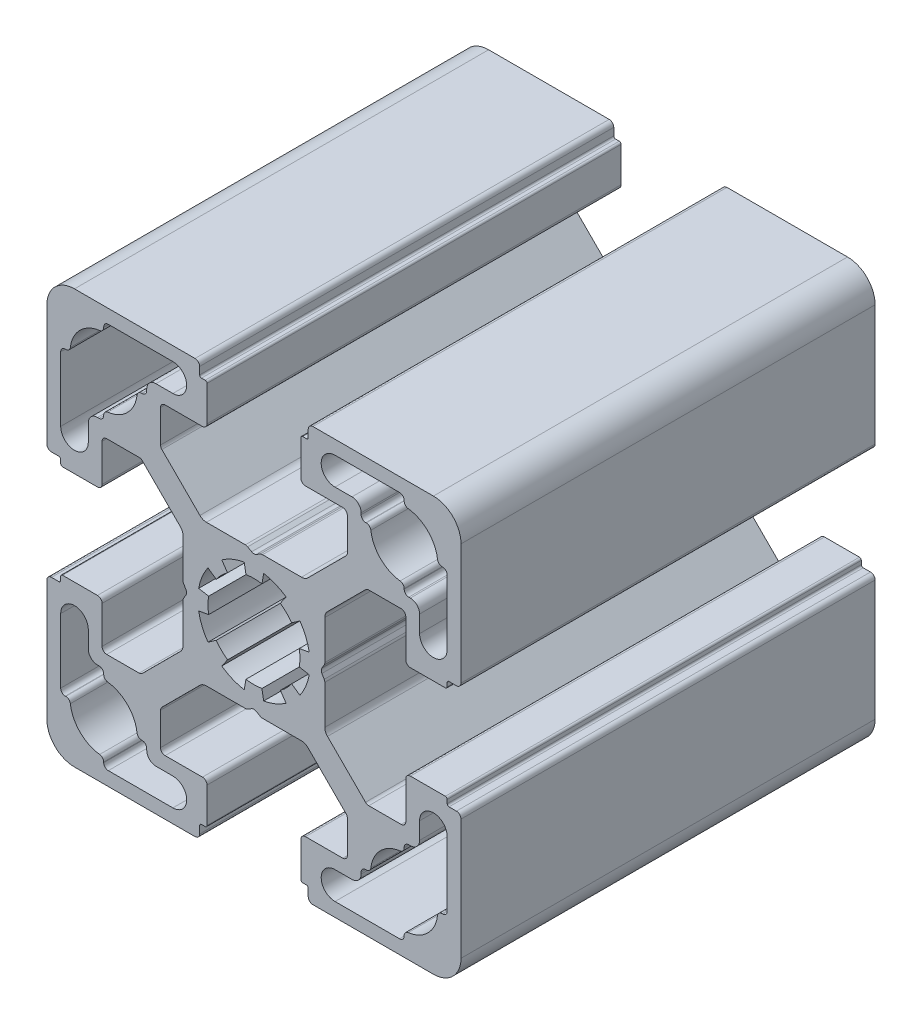
from build123d import *

# Parameters (mm, degrees)
EXTRUDE_4_DEPTH = 45


with BuildPart() as part:
    # Эскиз1 → Бобышка-Вытянуть4 (new body)
    with BuildSketch(Plane.XY):
        with BuildLine():
            Line((-7.700480433, 0.929088242), (-7.700480433, 5.164946528))
            ThreePointArc((-7.700480433, 5.164946528), (-7.776600901, 5.54762996), (-7.993373652, 5.872053309))
            Line((-7.993373652, 5.872053309), (-10.240131415, 8.118811071))
            Line((-10.240131415, 8.118811071), (-12.124873734, 10.003553391))
            ThreePointArc((-12.124873734, 10.003553391), (-12.287085409, 10.111939766), (-12.478427125, 10.15))
            Line((-12.478427125, 10.15), (-16, 10.15))
            ThreePointArc((-16, 10.15), (-16.353553391, 10.003553391), (-16.5, 9.65))
            Line((-16.5, 9.65), (-16.5, 5.6))
            ThreePointArc((-16.5, 5.6), (-16.646446609, 5.246446609), (-17, 5.1))
            Line((-17, 5.1), (-20.8, 5.1))
            ThreePointArc((-20.8, 5.1), (-20.941421356, 5.158578644), (-21, 5.3))
            Line((-21, 5.3), (-21, 5.7))
            ThreePointArc((-21, 5.7), (-21.058578644, 5.841421356), (-21.2, 5.9))
            Line((-21.2, 5.9), (-22, 5.9))
            ThreePointArc((-22, 5.9), (-22.353553391, 6.046446609), (-22.5, 6.4))
            Line((-22.5, 6.4), (-22.5, 19.5))
            ThreePointArc((-22.5, 19.5), (-21.621320344, 21.621320344), (-19.5, 22.5))
            Line((-19.5, 22.5), (-6.4, 22.5))
            ThreePointArc((-6.4, 22.5), (-6.046446609, 22.353553391), (-5.9, 22))
            Line((-5.9, 22), (-5.9, 21.2))
            ThreePointArc((-5.9, 21.2), (-5.841421356, 21.058578644), (-5.7, 21))
            Line((-5.7, 21), (-5.3, 21))
            ThreePointArc((-5.3, 21), (-5.158578644, 20.941421356), (-5.1, 20.8))
            Line((-5.1, 20.8), (-5.1, 17))
            ThreePointArc((-5.1, 17), (-5.246446609, 16.646446609), (-5.6, 16.5))
            Line((-5.6, 16.5), (-9.65, 16.5))
            ThreePointArc((-9.65, 16.5), (-10.003553391, 16.353553391), (-10.15, 16))
            Line((-10.15, 16), (-10.15, 12.478427125))
            ThreePointArc((-10.15, 12.478427125), (-10.111939766, 12.287085409), (-10.003553391, 12.124873734))
            Line((-10.003553391, 12.124873734), (-8.118811071, 10.240131415))
            Line((-8.118811071, 10.240131415), (-5.872053309, 7.993373652))
            ThreePointArc((-5.872053309, 7.993373652), (-5.54762996, 7.776600901), (-5.164946528, 7.700480433))
            Line((-5.164946528, 7.700480433), (-0.929088242, 7.700480433))
            ThreePointArc((-0.929088242, 7.700480433), (-0.799678719, 7.683443347), (-0.679088242, 7.633493135))
            Line((-0.679088242, 7.633493135), (-0.25, 7.385758924))
            ThreePointArc((-0.25, 7.385758924), (0, 7.318771625), (0.25, 7.385758924))
            Line((0.25, 7.385758924), (0.679088242, 7.633493135))
            ThreePointArc((0.679088242, 7.633493135), (0.799678719, 7.683443347), (0.929088242, 7.700480433))
            Line((0.929088242, 7.700480433), (5.164946528, 7.700480433))
            ThreePointArc((5.164946528, 7.700480433), (5.54762996, 7.776600901), (5.872053309, 7.993373652))
            Line((5.872053309, 7.993373652), (8.118811071, 10.240131415))
            Line((8.118811071, 10.240131415), (10.003553391, 12.124873734))
            ThreePointArc((10.003553391, 12.124873734), (10.111939766, 12.287085409), (10.15, 12.478427125))
            Line((10.15, 12.478427125), (10.15, 16))
            ThreePointArc((10.15, 16), (10.003553391, 16.353553391), (9.65, 16.5))
            Line((9.65, 16.5), (5.6, 16.5))
            ThreePointArc((5.6, 16.5), (5.246446609, 16.646446609), (5.1, 17))
            Line((5.1, 17), (5.1, 20.8))
            ThreePointArc((5.1, 20.8), (5.158578644, 20.941421356), (5.3, 21))
            Line((5.3, 21), (5.7, 21))
            ThreePointArc((5.7, 21), (5.841421356, 21.058578644), (5.9, 21.2))
            Line((5.9, 21.2), (5.9, 22))
            ThreePointArc((5.9, 22), (6.046446609, 22.353553391), (6.4, 22.5))
            Line((6.4, 22.5), (19.5, 22.5))
            ThreePointArc((19.5, 22.5), (21.621320344, 21.621320344), (22.5, 19.5))
            Line((22.5, 19.5), (22.5, 6.4))
            ThreePointArc((22.5, 6.4), (22.353553391, 6.046446609), (22, 5.9))
            Line((22, 5.9), (21.2, 5.9))
            ThreePointArc((21.2, 5.9), (21.058578644, 5.841421356), (21, 5.7))
            Line((21, 5.7), (21, 5.3))
            ThreePointArc((21, 5.3), (20.941421356, 5.158578644), (20.8, 5.1))
            Line((20.8, 5.1), (17, 5.1))
            ThreePointArc((17, 5.1), (16.646446609, 5.246446609), (16.5, 5.6))
            Line((16.5, 5.6), (16.5, 9.65))
            ThreePointArc((16.5, 9.65), (16.353553391, 10.003553391), (16, 10.15))
            Line((16, 10.15), (12.478427125, 10.15))
            ThreePointArc((12.478427125, 10.15), (12.287085409, 10.111939766), (12.124873734, 10.003553391))
            Line((12.124873734, 10.003553391), (10.240131415, 8.118811071))
            Line((10.240131415, 8.118811071), (7.993373652, 5.872053309))
            ThreePointArc((7.993373652, 5.872053309), (7.776600901, 5.54762996), (7.700480433, 5.164946528))
            Line((7.700480433, 5.164946528), (7.700480433, 0.929088242))
            ThreePointArc((7.700480433, 0.929088242), (7.683443347, 0.799678719), (7.633493135, 0.679088242))
            Line((7.633493135, 0.679088242), (7.385758924, 0.25))
            ThreePointArc((7.385758924, 0.25), (7.318771625, 0), (7.385758924, -0.25))
            Line((7.385758924, -0.25), (7.633493135, -0.679088242))
            ThreePointArc((7.633493135, -0.679088242), (7.683443347, -0.799678719), (7.700480433, -0.929088242))
            Line((7.700480433, -0.929088242), (7.700480433, -5.164946528))
            ThreePointArc((7.700480433, -5.164946528), (7.776600901, -5.54762996), (7.993373652, -5.872053309))
            Line((7.993373652, -5.872053309), (10.240131415, -8.118811071))
            Line((10.240131415, -8.118811071), (12.124873734, -10.003553391))
            ThreePointArc((12.124873734, -10.003553391), (12.287085409, -10.111939766), (12.478427125, -10.15))
            Line((12.478427125, -10.15), (16, -10.15))
            ThreePointArc((16, -10.15), (16.353553391, -10.003553391), (16.5, -9.65))
            Line((16.5, -9.65), (16.5, -5.6))
            ThreePointArc((16.5, -5.6), (16.646446609, -5.246446609), (17, -5.1))
            Line((17, -5.1), (20.8, -5.1))
            ThreePointArc((20.8, -5.1), (20.941421356, -5.158578644), (21, -5.3))
            Line((21, -5.3), (21, -5.7))
            ThreePointArc((21, -5.7), (21.058578644, -5.841421356), (21.2, -5.9))
            Line((21.2, -5.9), (22, -5.9))
            ThreePointArc((22, -5.9), (22.353553391, -6.046446609), (22.5, -6.4))
            Line((22.5, -6.4), (22.5, -19.5))
            ThreePointArc((22.5, -19.5), (21.621320344, -21.621320344), (19.5, -22.5))
            Line((19.5, -22.5), (6.4, -22.5))
            ThreePointArc((6.4, -22.5), (6.046446609, -22.353553391), (5.9, -22))
            Line((5.9, -22), (5.9, -21.2))
            ThreePointArc((5.9, -21.2), (5.841421356, -21.058578644), (5.7, -21))
            Line((5.7, -21), (5.3, -21))
            ThreePointArc((5.3, -21), (5.158578644, -20.941421356), (5.1, -20.8))
            Line((5.1, -20.8), (5.1, -17))
            ThreePointArc((5.1, -17), (5.246446609, -16.646446609), (5.6, -16.5))
            Line((5.6, -16.5), (9.65, -16.5))
            ThreePointArc((9.65, -16.5), (10.003553391, -16.353553391), (10.15, -16))
            Line((10.15, -16), (10.15, -12.478427125))
            ThreePointArc((10.15, -12.478427125), (10.111939766, -12.287085409), (10.003553391, -12.124873734))
            Line((10.003553391, -12.124873734), (8.118811071, -10.240131415))
            Line((8.118811071, -10.240131415), (5.872053309, -7.993373652))
            ThreePointArc((5.872053309, -7.993373652), (5.54762996, -7.776600901), (5.164946528, -7.700480433))
            Line((5.164946528, -7.700480433), (0.929088242, -7.700480433))
            ThreePointArc((0.929088242, -7.700480433), (0.799678719, -7.683443347), (0.679088242, -7.633493135))
            Line((0.679088242, -7.633493135), (0.25, -7.385758924))
            ThreePointArc((0.25, -7.385758924), (0, -7.318771625), (-0.25, -7.385758924))
            Line((-0.25, -7.385758924), (-0.679088242, -7.633493135))
            ThreePointArc((-0.679088242, -7.633493135), (-0.799678719, -7.683443347), (-0.929088242, -7.700480433))
            Line((-0.929088242, -7.700480433), (-5.164946528, -7.700480433))
            ThreePointArc((-5.164946528, -7.700480433), (-5.54762996, -7.776600901), (-5.872053309, -7.993373652))
            Line((-5.872053309, -7.993373652), (-8.118811071, -10.240131415))
            Line((-8.118811071, -10.240131415), (-10.003553391, -12.124873734))
            ThreePointArc((-10.003553391, -12.124873734), (-10.111939766, -12.287085409), (-10.15, -12.478427125))
            Line((-10.15, -12.478427125), (-10.15, -16))
            ThreePointArc((-10.15, -16), (-10.003553391, -16.353553391), (-9.65, -16.5))
            Line((-9.65, -16.5), (-5.6, -16.5))
            ThreePointArc((-5.6, -16.5), (-5.246446609, -16.646446609), (-5.1, -17))
            Line((-5.1, -17), (-5.1, -20.8))
            ThreePointArc((-5.1, -20.8), (-5.158578644, -20.941421356), (-5.3, -21))
            Line((-5.3, -21), (-5.7, -21))
            ThreePointArc((-5.7, -21), (-5.841421356, -21.058578644), (-5.9, -21.2))
            Line((-5.9, -21.2), (-5.9, -22))
            ThreePointArc((-5.9, -22), (-6.046446609, -22.353553391), (-6.4, -22.5))
            Line((-6.4, -22.5), (-19.5, -22.5))
            ThreePointArc((-19.5, -22.5), (-21.621320344, -21.621320344), (-22.5, -19.5))
            Line((-22.5, -19.5), (-22.5, -6.4))
            ThreePointArc((-22.5, -6.4), (-22.353553391, -6.046446609), (-22, -5.9))
            Line((-22, -5.9), (-21.2, -5.9))
            ThreePointArc((-21.2, -5.9), (-21.058578644, -5.841421356), (-21, -5.7))
            Line((-21, -5.7), (-21, -5.3))
            ThreePointArc((-21, -5.3), (-20.941421356, -5.158578644), (-20.8, -5.1))
            Line((-20.8, -5.1), (-17, -5.1))
            ThreePointArc((-17, -5.1), (-16.646446609, -5.246446609), (-16.5, -5.6))
            Line((-16.5, -5.6), (-16.5, -9.65))
            ThreePointArc((-16.5, -9.65), (-16.353553391, -10.003553391), (-16, -10.15))
            Line((-16, -10.15), (-12.478427125, -10.15))
            ThreePointArc((-12.478427125, -10.15), (-12.287085409, -10.111939766), (-12.124873734, -10.003553391))
            Line((-12.124873734, -10.003553391), (-10.240131415, -8.118811071))
            Line((-10.240131415, -8.118811071), (-7.993373652, -5.872053309))
            ThreePointArc((-7.993373652, -5.872053309), (-7.776600901, -5.54762996), (-7.700480433, -5.164946528))
            Line((-7.700480433, -5.164946528), (-7.700480433, -0.929088242))
            ThreePointArc((-7.700480433, -0.929088242), (-7.683443347, -0.799678719), (-7.633493135, -0.679088242))
            Line((-7.633493135, -0.679088242), (-7.385758924, -0.25))
            ThreePointArc((-7.385758924, -0.25), (-7.318771625, 0), (-7.385758924, 0.25))
            Line((-7.385758924, 0.25), (-7.633493135, 0.679088242))
            ThreePointArc((-7.633493135, 0.679088242), (-7.683443347, 0.799678719), (-7.700480433, 0.929088242))
        make_face()
        with BuildLine():
            Line((-21, 15.825), (-21, 8.807951074))
            ThreePointArc((-21, 8.807951074), (-19.5, 7.307951074), (-18, 8.807951074))
            Line((-18, 8.807951074), (-18, 10.65))
            ThreePointArc((-18, 10.65), (-17.707106781, 11.357106781), (-17, 11.65))
            Line((-17, 11.65), (-16.825, 11.65))
            ThreePointArc((-16.825, 11.65), (-16.471446609, 11.796446609), (-16.325, 12.15))
            Line((-16.325, 12.15), (-16.325, 12.205230589))
            ThreePointArc((-16.325, 12.205230589), (-16.19924623, 12.536802239), (-15.885240964, 12.701588349))
            ThreePointArc((-15.885240964, 12.701588349), (-13.744060249, 13.744060249), (-12.701588349, 15.885240964))
            ThreePointArc((-12.701588349, 15.885240964), (-12.536802239, 16.19924623), (-12.205230589, 16.325))
            Line((-12.205230589, 16.325), (-12.15, 16.325))
            ThreePointArc((-12.15, 16.325), (-11.796446609, 16.471446609), (-11.65, 16.825))
            Line((-11.65, 16.825), (-11.65, 17))
            ThreePointArc((-11.65, 17), (-11.357106781, 17.707106781), (-10.65, 18))
            Line((-10.65, 18), (-8.807951074, 18))
            ThreePointArc((-8.807951074, 18), (-7.307951074, 19.5), (-8.807951074, 21))
            Line((-8.807951074, 21), (-15.825, 21))
            ThreePointArc((-15.825, 21), (-16.178553391, 20.853553391), (-16.325, 20.5))
            Line((-16.325, 20.5), (-16.325, 20.444769411))
            ThreePointArc((-16.325, 20.444769411), (-16.45075377, 20.113197761), (-16.764759036, 19.948411651))
            ThreePointArc((-16.764759036, 19.948411651), (-18.905939751, 18.905939751), (-19.948411651, 16.764759036))
            ThreePointArc((-19.948411651, 16.764759036), (-20.113197761, 16.45075377), (-20.444769411, 16.325))
            Line((-20.444769411, 16.325), (-20.5, 16.325))
            ThreePointArc((-20.5, 16.325), (-20.853553391, 16.178553391), (-21, 15.825))
        make_face(mode=Mode.SUBTRACT)
        with BuildLine():
            Line((-15.825, -21), (-8.807951074, -21))
            ThreePointArc((-8.807951074, -21), (-7.307951074, -19.5), (-8.807951074, -18))
            Line((-8.807951074, -18), (-10.65, -18))
            ThreePointArc((-10.65, -18), (-11.357106781, -17.707106781), (-11.65, -17))
            Line((-11.65, -17), (-11.65, -16.825))
            ThreePointArc((-11.65, -16.825), (-11.796446609, -16.471446609), (-12.15, -16.325))
            Line((-12.15, -16.325), (-12.205230589, -16.325))
            ThreePointArc((-12.205230589, -16.325), (-12.536802239, -16.19924623), (-12.701588349, -15.885240964))
            ThreePointArc((-12.701588349, -15.885240964), (-13.744060249, -13.744060249), (-15.885240964, -12.701588349))
            ThreePointArc((-15.885240964, -12.701588349), (-16.19924623, -12.536802239), (-16.325, -12.205230589))
            Line((-16.325, -12.205230589), (-16.325, -12.15))
            ThreePointArc((-16.325, -12.15), (-16.471446609, -11.796446609), (-16.825, -11.65))
            Line((-16.825, -11.65), (-17, -11.65))
            ThreePointArc((-17, -11.65), (-17.707106781, -11.357106781), (-18, -10.65))
            Line((-18, -10.65), (-18, -8.807951074))
            ThreePointArc((-18, -8.807951074), (-19.5, -7.307951074), (-21, -8.807951074))
            Line((-21, -8.807951074), (-21, -15.825))
            ThreePointArc((-21, -15.825), (-20.853553391, -16.178553391), (-20.5, -16.325))
            Line((-20.5, -16.325), (-20.444769411, -16.325))
            ThreePointArc((-20.444769411, -16.325), (-20.113197761, -16.45075377), (-19.948411651, -16.764759036))
            ThreePointArc((-19.948411651, -16.764759036), (-18.905939751, -18.905939751), (-16.764759036, -19.948411651))
            ThreePointArc((-16.764759036, -19.948411651), (-16.45075377, -20.113197761), (-16.325, -20.444769411))
            Line((-16.325, -20.444769411), (-16.325, -20.5))
            ThreePointArc((-16.325, -20.5), (-16.178553391, -20.853553391), (-15.825, -21))
        make_face(mode=Mode.SUBTRACT)
        with BuildLine():
            Line((15.825, 21), (8.807951074, 21))
            ThreePointArc((8.807951074, 21), (7.307951074, 19.5), (8.807951074, 18))
            Line((8.807951074, 18), (10.65, 18))
            ThreePointArc((10.65, 18), (11.357106781, 17.707106781), (11.65, 17))
            Line((11.65, 17), (11.65, 16.825))
            ThreePointArc((11.65, 16.825), (11.796446609, 16.471446609), (12.15, 16.325))
            Line((12.15, 16.325), (12.205230589, 16.325))
            ThreePointArc((12.205230589, 16.325), (12.536802239, 16.19924623), (12.701588349, 15.885240964))
            ThreePointArc((12.701588349, 15.885240964), (13.744060249, 13.744060249), (15.885240964, 12.701588349))
            ThreePointArc((15.885240964, 12.701588349), (16.19924623, 12.536802239), (16.325, 12.205230589))
            Line((16.325, 12.205230589), (16.325, 12.15))
            ThreePointArc((16.325, 12.15), (16.471446609, 11.796446609), (16.825, 11.65))
            Line((16.825, 11.65), (17, 11.65))
            ThreePointArc((17, 11.65), (17.707106781, 11.357106781), (18, 10.65))
            Line((18, 10.65), (18, 8.807951074))
            ThreePointArc((18, 8.807951074), (19.5, 7.307951074), (21, 8.807951074))
            Line((21, 8.807951074), (21, 15.825))
            ThreePointArc((21, 15.825), (20.853553391, 16.178553391), (20.5, 16.325))
            Line((20.5, 16.325), (20.444769411, 16.325))
            ThreePointArc((20.444769411, 16.325), (20.113197761, 16.45075377), (19.948411651, 16.764759036))
            ThreePointArc((19.948411651, 16.764759036), (18.905939751, 18.905939751), (16.764759036, 19.948411651))
            ThreePointArc((16.764759036, 19.948411651), (16.45075377, 20.113197761), (16.325, 20.444769411))
            Line((16.325, 20.444769411), (16.325, 20.5))
            ThreePointArc((16.325, 20.5), (16.178553391, 20.853553391), (15.825, 21))
        make_face(mode=Mode.SUBTRACT)
        with BuildLine():
            Line((-2.867882182, 4.095760221), (-3.498816262, 4.99682747))
            ThreePointArc((-3.498816262, 4.99682747), (-2.334368937, 5.635665148), (-1.059253884, 6.007327293))
            Line((-1.059253884, 6.007327293), (-0.868240888, 4.924038765))
            ThreePointArc((-0.868240888, 4.924038765), (0, 5), (0.868240888, 4.924038765))
            Line((0.868240888, 4.924038765), (1.059253884, 6.007327293))
            ThreePointArc((1.059253884, 6.007327293), (2.334368937, 5.635665148), (3.498816262, 4.99682747))
            Line((3.498816262, 4.99682747), (2.867882182, 4.095760221))
            ThreePointArc((2.867882182, 4.095760221), (3.535533906, 3.535533906), (4.095760221, 2.867882182))
            Line((4.095760221, 2.867882182), (4.99682747, 3.498816262))
            ThreePointArc((4.99682747, 3.498816262), (5.635665148, 2.334368937), (6.007327293, 1.059253884))
            Line((6.007327293, 1.059253884), (4.924038765, 0.868240888))
            ThreePointArc((4.924038765, 0.868240888), (5, 0), (4.924038765, -0.868240888))
            Line((4.924038765, -0.868240888), (6.007327293, -1.059253884))
            ThreePointArc((6.007327293, -1.059253884), (5.635665148, -2.334368937), (4.99682747, -3.498816262))
            Line((4.99682747, -3.498816262), (4.095760221, -2.867882182))
            ThreePointArc((4.095760221, -2.867882182), (3.535533906, -3.535533906), (2.867882182, -4.095760221))
            Line((2.867882182, -4.095760221), (3.498816262, -4.99682747))
            ThreePointArc((3.498816262, -4.99682747), (2.334368937, -5.635665148), (1.059253884, -6.007327293))
            Line((1.059253884, -6.007327293), (0.868240888, -4.924038765))
            ThreePointArc((0.868240888, -4.924038765), (0, -5), (-0.868240888, -4.924038765))
            Line((-0.868240888, -4.924038765), (-1.059253884, -6.007327293))
            ThreePointArc((-1.059253884, -6.007327293), (-2.334368937, -5.635665148), (-3.498816262, -4.99682747))
            Line((-3.498816262, -4.99682747), (-2.867882182, -4.095760221))
            ThreePointArc((-2.867882182, -4.095760221), (-3.535533906, -3.535533906), (-4.095760221, -2.867882182))
            Line((-4.095760221, -2.867882182), (-4.99682747, -3.498816262))
            ThreePointArc((-4.99682747, -3.498816262), (-5.635665148, -2.334368937), (-6.007327293, -1.059253884))
            Line((-6.007327293, -1.059253884), (-4.924038765, -0.868240888))
            ThreePointArc((-4.924038765, -0.868240888), (-5, 0), (-4.924038765, 0.868240888))
            Line((-4.924038765, 0.868240888), (-6.007327293, 1.059253884))
            ThreePointArc((-6.007327293, 1.059253884), (-5.635665148, 2.334368937), (-4.99682747, 3.498816262))
            Line((-4.99682747, 3.498816262), (-4.095760221, 2.867882182))
            ThreePointArc((-4.095760221, 2.867882182), (-3.535533906, 3.535533906), (-2.867882182, 4.095760221))
        make_face(mode=Mode.SUBTRACT)
        with BuildLine():
            Line((21, -15.825), (21, -8.807951074))
            ThreePointArc((21, -8.807951074), (19.5, -7.307951074), (18, -8.807951074))
            Line((18, -8.807951074), (18, -10.65))
            ThreePointArc((18, -10.65), (17.707106781, -11.357106781), (17, -11.65))
            Line((17, -11.65), (16.825, -11.65))
            ThreePointArc((16.825, -11.65), (16.471446609, -11.796446609), (16.325, -12.15))
            Line((16.325, -12.15), (16.325, -12.205230589))
            ThreePointArc((16.325, -12.205230589), (16.19924623, -12.536802239), (15.885240964, -12.701588349))
            ThreePointArc((15.885240964, -12.701588349), (13.744060249, -13.744060249), (12.701588349, -15.885240964))
            ThreePointArc((12.701588349, -15.885240964), (12.536802239, -16.19924623), (12.205230589, -16.325))
            Line((12.205230589, -16.325), (12.15, -16.325))
            ThreePointArc((12.15, -16.325), (11.796446609, -16.471446609), (11.65, -16.825))
            Line((11.65, -16.825), (11.65, -17))
            ThreePointArc((11.65, -17), (11.357106781, -17.707106781), (10.65, -18))
            Line((10.65, -18), (8.807951074, -18))
            ThreePointArc((8.807951074, -18), (7.307951074, -19.5), (8.807951074, -21))
            Line((8.807951074, -21), (15.825, -21))
            ThreePointArc((15.825, -21), (16.178553391, -20.853553391), (16.325, -20.5))
            Line((16.325, -20.5), (16.325, -20.444769411))
            ThreePointArc((16.325, -20.444769411), (16.45075377, -20.113197761), (16.764759036, -19.948411651))
            ThreePointArc((16.764759036, -19.948411651), (18.905939751, -18.905939751), (19.948411651, -16.764759036))
            ThreePointArc((19.948411651, -16.764759036), (20.113197761, -16.45075377), (20.444769411, -16.325))
            Line((20.444769411, -16.325), (20.5, -16.325))
            ThreePointArc((20.5, -16.325), (20.853553391, -16.178553391), (21, -15.825))
        make_face(mode=Mode.SUBTRACT)
    extrude(amount=EXTRUDE_4_DEPTH)


solid = part.part
